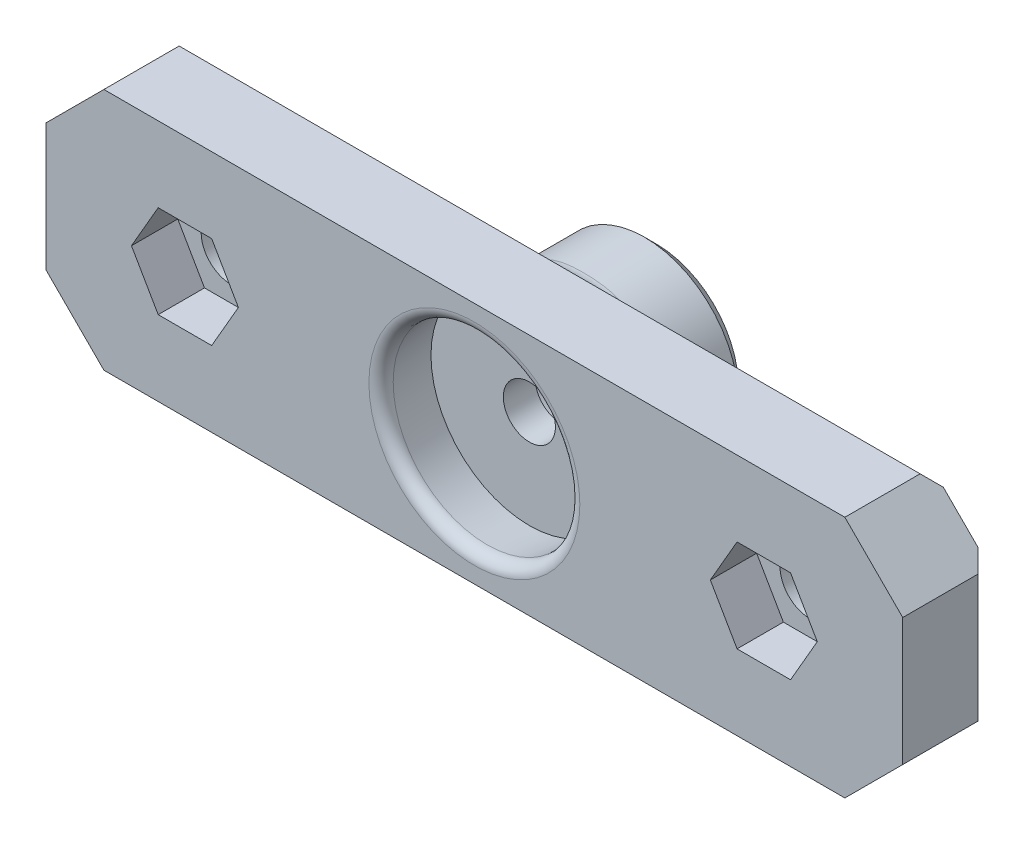
from build123d import *

# Parameters (mm, degrees)
SKETCH1_W           = 74
SKETCH1_H           = 21
BOSS_EXTRUDE1_DEPTH = 7.5
SKETCH2_R           = 8
CUT_EXTRUDE1_DEPTH  = 4.75
CUT_EXTRUDE1_TAPER  = -6
SKETCH4_R           = 2.6
CUT_EXTRUDE4_DEPTH  = 8.5000001
CHAMFER3_SIZE       = 5
CUT_EXTRUDE6_DEPTH  = 4
SKETCH11_R          = 2.25
CUT_EXTRUDE10_DEPTH = 8.5
FILLET4_R           = 1
FILLET5_R           = 1
CHAMFER5_SIZE       = 1
SKETCH12_R          = 8.1
SKETCH12_R_2        = 6.1
EXTRUDE_THIN1_DEPTH = 8.2
FILLET6_R           = 2
CHAMFER6_SIZE       = 1


with BuildPart() as part:
    # Sketch1 → Boss-Extrude1 (new body)
    with BuildSketch(Plane.XY):
        Rectangle(SKETCH1_W, SKETCH1_H)
    extrude(amount=BOSS_EXTRUDE1_DEPTH)

    # Sketch2 → Cut-Extrude1 (cut)
    with BuildSketch(Plane.XY.offset(7.5)):
        Circle(SKETCH2_R)
    extrude(amount=-CUT_EXTRUDE1_DEPTH, taper=CUT_EXTRUDE1_TAPER, mode=Mode.SUBTRACT)

    # Sketch4 → Cut-Extrude4 (cut, through all)
    with BuildSketch(Plane(origin=(0, 0, 0), x_dir=(-1, 0, 0), z_dir=(0, 0, -1))):
        with Locations((-25, 0)):
            Circle(SKETCH4_R)
        with Locations((25, 0)):
            Circle(SKETCH4_R)
    extrude(amount=-CUT_EXTRUDE4_DEPTH, mode=Mode.SUBTRACT)

    # Chamfer3
    chamfer3_edges = [part.edges().sort_by_distance(p)[0] for p in [
        (37, -10.5, 3.75),
        (-37, -10.5, 3.75),
        (-37, 10.5, 3.75),
        (37, 10.5, 3.75),
    ]]
    chamfer(chamfer3_edges, length=CHAMFER3_SIZE)

    # Sketch5 → Cut-Extrude6 (cut)
    with BuildSketch(Plane.XY.offset(7.5)):
        Polygon((22.690598923, -4), (27.309401077, -4), (29.618802154, 0), (27.309401077, 4), (22.690598923, 4), (20.381197846, 0), align=None)
        Polygon((-27.309401077, -4), (-22.690598923, -4), (-20.381197846, 0), (-22.690598923, 4), (-27.309401077, 4), (-29.618802154, 0), align=None)
    extrude(amount=-CUT_EXTRUDE6_DEPTH, mode=Mode.SUBTRACT)

    # Sketch11 → Cut-Extrude10 (cut, through all)
    with BuildSketch(Plane.XY.offset(7.5)):
        Circle(SKETCH11_R)
    extrude(amount=-CUT_EXTRUDE10_DEPTH, mode=Mode.SUBTRACT)

    # Fillet4
    fillet4_edges = [part.edges().sort_by_distance(p)[0] for p in [
        (27.6, 0, 0),
        (-22.4, 0, 0),
    ]]
    fillet(fillet4_edges, radius=FILLET4_R)

    # Fillet5
    fillet5_edges = [part.edges().sort_by_distance(p)[0] for p in [
        (-8, 0, 7.5),
    ]]
    fillet(fillet5_edges, radius=FILLET5_R)

    # Chamfer5
    chamfer5_edges = [part.edges().sort_by_distance(p)[0] for p in [
        (-37, 0, 0),
        (37, 0, 0),
        (0, -10.5, 0),
        (0, 10.5, 0),
    ]]
    chamfer(chamfer5_edges, length=CHAMFER5_SIZE)

    # Sketch12 → Extrude-Thin1 (add)
    with BuildSketch(Plane(origin=(0, 0, 0), x_dir=(-1, 0, 0), z_dir=(0, 0, -1))):
        Circle(SKETCH12_R)
        Circle(SKETCH12_R_2, mode=Mode.SUBTRACT)
    extrude(amount=EXTRUDE_THIN1_DEPTH)

    # Fillet6
    fillet6_edges = [part.edges().sort_by_distance(p)[0] for p in [
        (8.1, 0, 0),
    ]]
    fillet(fillet6_edges, radius=FILLET6_R)

    # Chamfer6
    chamfer6_edges = [part.edges().sort_by_distance(p)[0] for p in [
        (8.1, 0, -8.2),
    ]]
    chamfer(chamfer6_edges, length=CHAMFER6_SIZE)


solid = part.part
